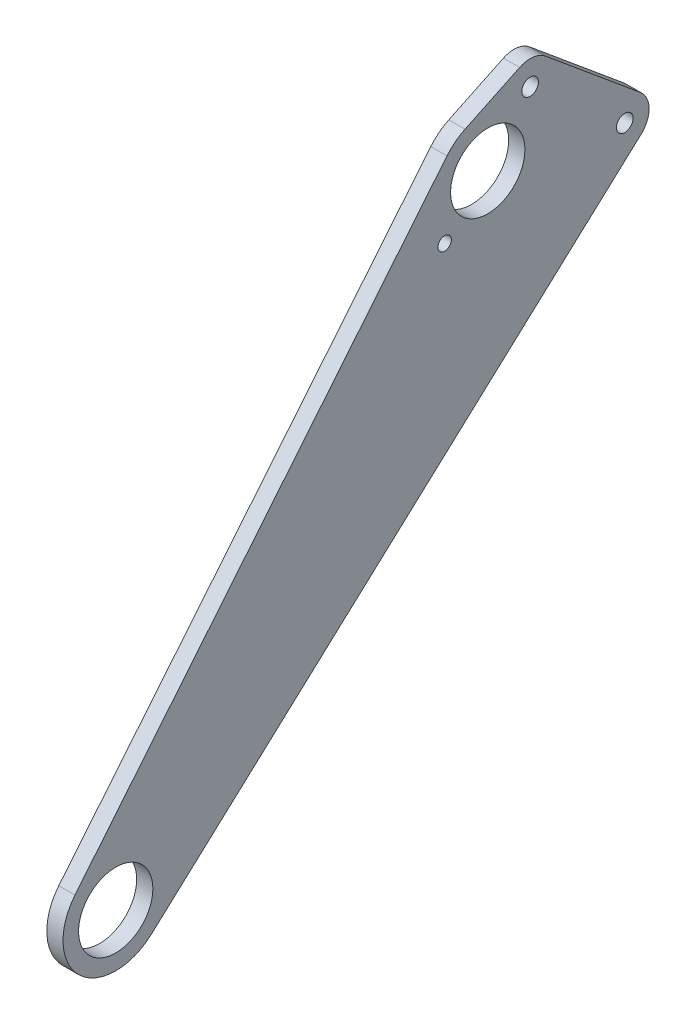
from build123d import *

# Parameters (mm, degrees)
SKETCH1_R           = 14.5542
SKETCH1_R_2         = 3.2639
SKETCH1_R_3         = 2.6289
BOSS_EXTRUDE1_DEPTH = 6.35


with BuildPart() as part:
    # Sketch1 → Boss-Extrude1 (new body)
    with BuildSketch(Plane(origin=(0, 0, 0), x_dir=(0, 0, -1), z_dir=(1, 0, 0))):
        with BuildLine():
            Line((-15.963866107, 13.079043741), (129.797045986, 190.990191551))
            ThreePointArc((129.797045986, 190.990191551), (133.020825181, 194.146805841), (136.853539845, 196.527407527))
            Line((136.853539845, 196.527407527), (158.250141957, 206.765097738))
            ThreePointArc((158.250141957, 206.765097738), (163.53580513, 207.625279933), (168.450190134, 205.497612521))
            Line((168.450190134, 205.497612521), (205.528624059, 174.674388835))
            ThreePointArc((205.528624059, 174.674388835), (208.962008043, 167.574960267), (205.86808218, 160.321158896))
            Line((205.86808218, 160.321158896), (13.92822473, -15.22862312))
            ThreePointArc((13.92822473, -15.22862312), (-14.190382649, -14.984640353), (-15.963866107, 13.079043741))
        make_face()
        Circle(SKETCH1_R, mode=Mode.SUBTRACT)
        with Locations((145.760912093, 177.911147809)):
            Circle(SKETCH1_R, mode=Mode.SUBTRACT)
        with Locations((199.439670766, 167.349754182)):
            Circle(SKETCH1_R_2, mode=Mode.SUBTRACT)
        with Locations((162.361236841, 198.172977868)):
            Circle(SKETCH1_R_2, mode=Mode.SUBTRACT)
        with Locations((128.876648593, 161.759110908)):
            Circle(SKETCH1_R_3, mode=Mode.SUBTRACT)
    extrude(amount=BOSS_EXTRUDE1_DEPTH)


solid = part.part
